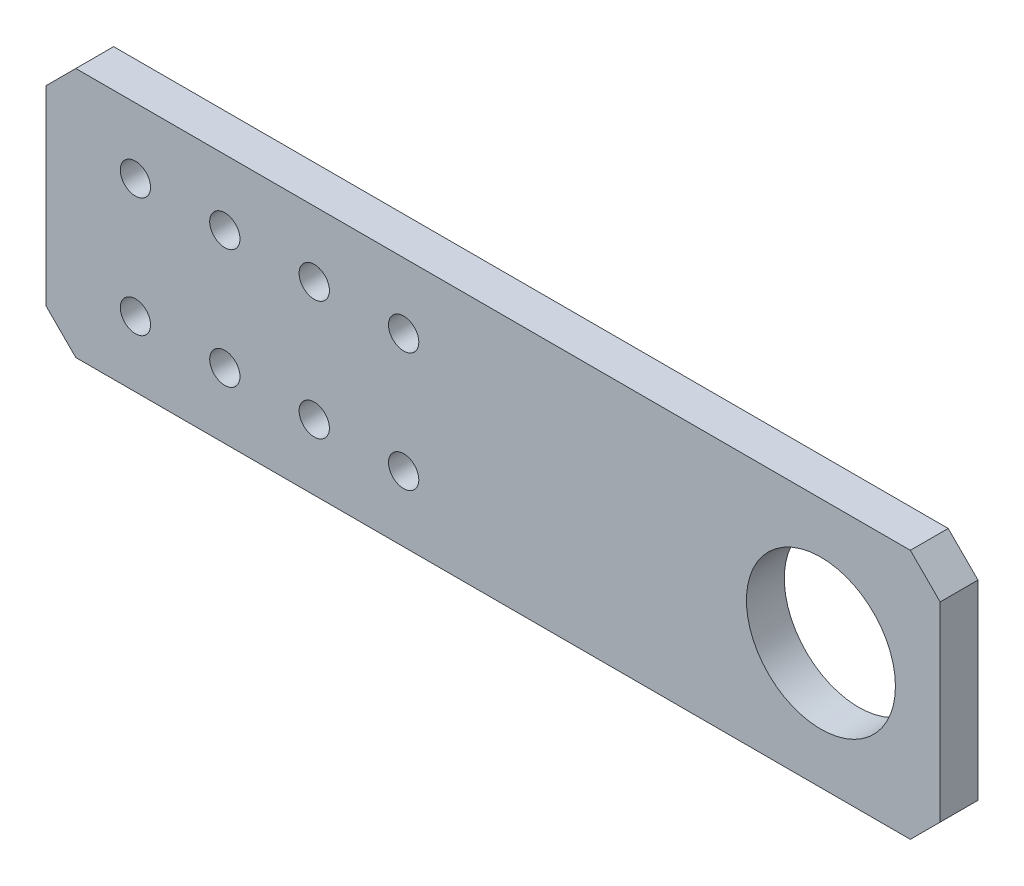
from build123d import *

# Parameters (mm, degrees)
SKETCH1_W           = 200
SKETCH1_H           = 42
BOSS_EXTRUDE1_DEPTH = 6.35
SKETCH3_R           = 2
CUT_EXTRUDE2_DEPTH  = 103.378330227
SKETCH4_R           = 3.175
CUT_EXTRUDE3_DEPTH  = 103.378330227
CHAMFER1_SIZE       = 5
SKETCH9_R           = 3.175
CUT_EXTRUDE8_DEPTH  = 103.378330227
SKETCH10_R          = 12.5
CUT_EXTRUDE9_DEPTH  = 103.378330227
SKETCH12_R          = 3.302
CUT_EXTRUDE11_DEPTH = 103.378330227
SKETCH13_R          = 2
SKETCH13_R_2        = 3.302
SKETCH13_R_3        = 3.175
SKETCH13_R_4        = 2.54
CUT_EXTRUDE12_DEPTH = 10


with BuildPart() as part:
    # Sketch1 → Boss-Extrude1 (new body)
    with BuildSketch(Plane.XY):
        Rectangle(SKETCH1_W, SKETCH1_H)
    extrude(amount=BOSS_EXTRUDE1_DEPTH)

    # Sketch3 → Cut-Extrude2 (cut, through all)
    with BuildSketch(Plane.XY.offset(6.35)):
        with Locations((-55, 10)):
            Circle(SKETCH3_R)
        with Locations((-55, -10)):
            Circle(SKETCH3_R)
    extrude(amount=-CUT_EXTRUDE2_DEPTH, mode=Mode.SUBTRACT)

    # Sketch4 → Cut-Extrude3 (cut, through all)
    with BuildSketch(Plane.XY.offset(6.35)):
        with Locations((-76, 0)):
            Circle(SKETCH4_R)
    extrude(amount=-CUT_EXTRUDE3_DEPTH, mode=Mode.SUBTRACT)

    # Chamfer1
    chamfer1_edges = [part.edges().sort_by_distance(p)[0] for p in [
        (100, -21, 3.175),
        (-100, -21, 3.175),
        (-100, 21, 3.175),
        (100, 21, 3.175),
    ]]
    chamfer(chamfer1_edges, length=CHAMFER1_SIZE)

    # Sketch9 → Cut-Extrude8 (cut, through all)
    with BuildSketch(Plane.XY.offset(6.35)):
        with Locations((80, 0)):
            Circle(SKETCH9_R)
    extrude(amount=-CUT_EXTRUDE8_DEPTH, mode=Mode.SUBTRACT)

    # Sketch10 → Cut-Extrude9 (cut, through all)
    with BuildSketch(Plane.XY.offset(6.35)):
        with Locations((80, 0)):
            Circle(SKETCH10_R)
    extrude(amount=-CUT_EXTRUDE9_DEPTH, mode=Mode.SUBTRACT)

    # Sketch12 → Cut-Extrude11 (cut, through all)
    with BuildSketch(Plane.XY.offset(6.35)):
        with Locations((-93, 0)):
            Circle(SKETCH12_R)
    extrude(amount=-CUT_EXTRUDE11_DEPTH, mode=Mode.SUBTRACT)

    # Sketch13 → Cut-Extrude12 (cut)
    with BuildSketch(Plane.XY.offset(6.35)):
        Polygon((-50, -16), (-50, 16), (-45, 21), (-95, 21), (-100, 16), (-100, -16), (-95, -21), (-45, -21), align=None)
        with Locations((-55, -10)):
            Circle(SKETCH13_R, mode=Mode.SUBTRACT)
        with Locations((-93, 0)):
            Circle(SKETCH13_R_2, mode=Mode.SUBTRACT)
        with Locations((-76, 0)):
            Circle(SKETCH13_R_3, mode=Mode.SUBTRACT)
        with Locations((-55, 10)):
            Circle(SKETCH13_R, mode=Mode.SUBTRACT)
        with Locations((-35, 10)):
            Circle(SKETCH13_R_4)
        with Locations((-20, 10)):
            Circle(SKETCH13_R_4)
        with Locations((-5, 10)):
            Circle(SKETCH13_R_4)
        with Locations((10, 10)):
            Circle(SKETCH13_R_4)
        with Locations((-20, -10)):
            Circle(SKETCH13_R_4)
        with Locations((-5, -10)):
            Circle(SKETCH13_R_4)
        with Locations((10, -10)):
            Circle(SKETCH13_R_4)
        with Locations((-35, -10)):
            Circle(SKETCH13_R_4)
    extrude(amount=-CUT_EXTRUDE12_DEPTH, mode=Mode.SUBTRACT)


solid = part.part
